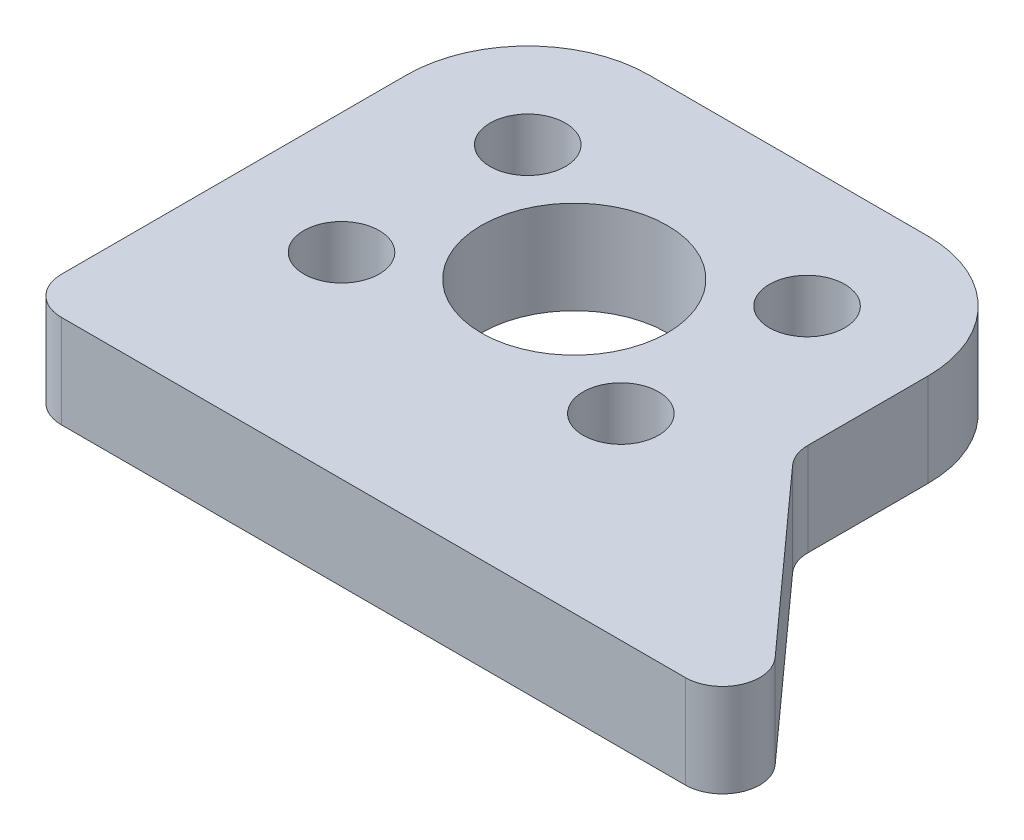
from build123d import *

# Parameters (mm, degrees)
SKETCH_1_R          = 2.025
EXTRUDE_1_DEPTH     = 5
FILLET_1_R          = 2
SKETCH_2_R          = 5
CUT_EXTRUDE_1_DEPTH = 5


with BuildPart() as part:
    # 草图1 → 凸台-拉伸1 (new body)
    with BuildSketch(Plane(origin=(0, 0, 0), x_dir=(1, 0, 0), z_dir=(0, 1, 0))):
        with BuildLine():
            Line((7.5, 11.5), (-7.5, 11.5))
            ThreePointArc((-7.5, 11.5), (-12.096194078, 9.596194078), (-14, 5))
            Line((-14, 5), (-14, -15.546331524))
            Line((-14, -15.546331524), (26, -15.546331524))
            Line((26, -15.546331524), (14, -2.218981346))
            Line((14, -2.218981346), (14, 5))
            ThreePointArc((14, 5), (12.096194078, 9.596194078), (7.5, 11.5))
        make_face()
        with Locations((-7.5, -5)):
            Circle(SKETCH_1_R, mode=Mode.SUBTRACT)
        with Locations((7.5, -5)):
            Circle(SKETCH_1_R, mode=Mode.SUBTRACT)
        with Locations((-7.5, 5)):
            Circle(SKETCH_1_R, mode=Mode.SUBTRACT)
        with Locations((7.5, 5)):
            Circle(SKETCH_1_R, mode=Mode.SUBTRACT)
    extrude(amount=EXTRUDE_1_DEPTH)

    # 圆角1
    fillet_1_edges = [part.edges().sort_by_distance(p)[0] for p in [
        (14, 2.5, 2.218981346),
        (26, 2.5, 15.546331524),
        (-14, 2.5, 15.546331524),
    ]]
    fillet(fillet_1_edges, radius=FILLET_1_R)

    # 草图2 → 切除-拉伸1 (cut)
    with BuildSketch(Plane(origin=(0, 5, 0), x_dir=(1, 0, 0), z_dir=(0, 1, 0))):
        Circle(SKETCH_2_R)
    extrude(amount=-CUT_EXTRUDE_1_DEPTH, mode=Mode.SUBTRACT)


solid = part.part
